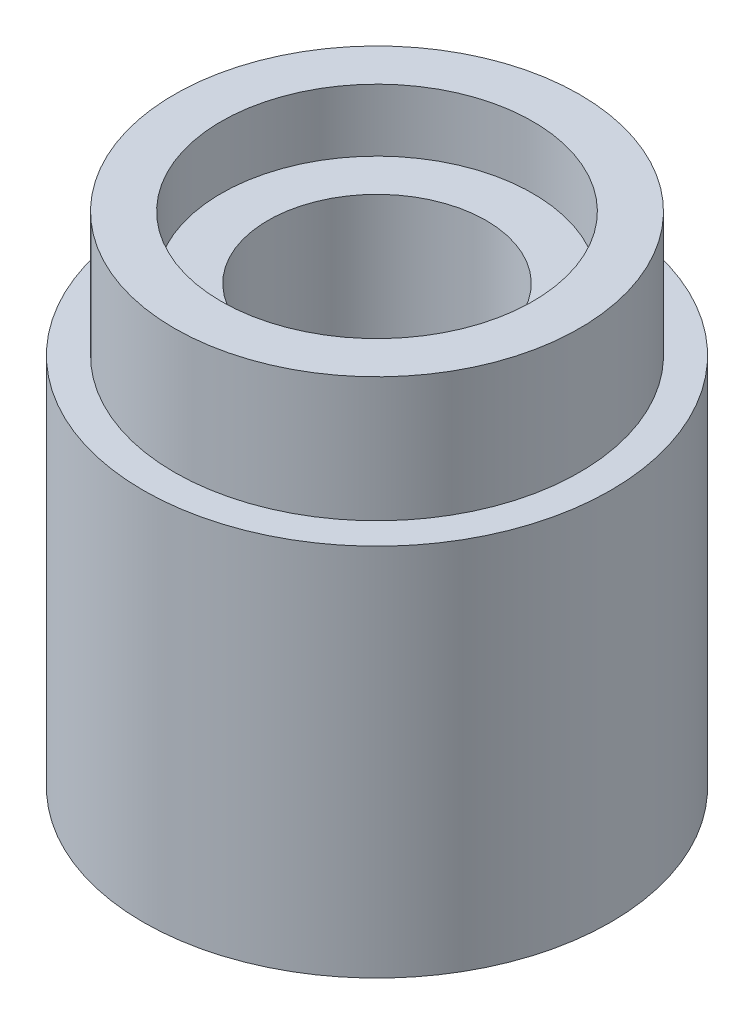
from build123d import *

# Parameters (mm, degrees)
SKETCH1_R           = 3.75
BOSS_EXTRUDE1_DEPTH = 8
SKETCH3_R           = 3.75
SKETCH3_R_2         = 3.25
CUT_EXTRUDE1_DEPTH  = 2
SKETCH4_R           = 1.75
CUT_EXTRUDE2_DEPTH  = 7.5
SKETCH5_R           = 2.5
CUT_EXTRUDE3_DEPTH  = 1


with BuildPart() as part:
    # Sketch1 → Boss-Extrude1 (new body)
    with BuildSketch(Plane(origin=(0, 0, 0), x_dir=(1, 0, 0), z_dir=(0, 1, 0))):
        Circle(SKETCH1_R)
    extrude(amount=BOSS_EXTRUDE1_DEPTH)

    # Sketch3 → Cut-Extrude1 (cut)
    with BuildSketch(Plane(origin=(0, 8, 0), x_dir=(1, 0, 0), z_dir=(0, 1, 0))):
        Circle(SKETCH3_R)
        Circle(SKETCH3_R_2, mode=Mode.SUBTRACT)
    extrude(amount=-CUT_EXTRUDE1_DEPTH, mode=Mode.SUBTRACT)

    # Sketch4 → Cut-Extrude2 (cut)
    with BuildSketch(Plane(origin=(0, 8, 0), x_dir=(1, 0, 0), z_dir=(0, 1, 0))):
        Circle(SKETCH4_R)
    extrude(amount=-CUT_EXTRUDE2_DEPTH, mode=Mode.SUBTRACT)

    # Sketch5 → Cut-Extrude3 (cut)
    with BuildSketch(Plane(origin=(0, 8, 0), x_dir=(1, 0, 0), z_dir=(0, 1, 0))):
        Circle(SKETCH5_R)
    extrude(amount=-CUT_EXTRUDE3_DEPTH, mode=Mode.SUBTRACT)


solid = part.part
